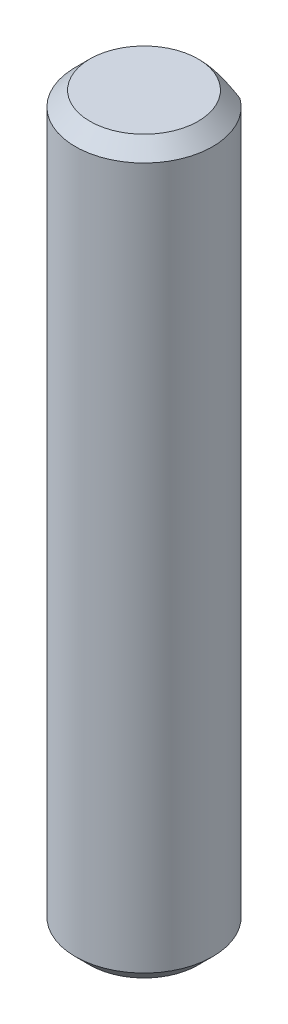
from build123d import *

# Parameters (mm, degrees)
CUT_EXTRUDE1_DEPTH = 26


with BuildPart() as part:
    # Sketch1 → Revolve1 (revolve)
    with BuildSketch(Plane.XY):
        Polygon((0, -12.5), (-1.85, -12.5), (-2.35, -12), (-2.35, 12), (-1.85, 12.5), (0, 12.5), align=None)
    revolve(axis=Axis((0, 12.5, 0), (0, -1, 0)))

    # Sketch2 → Cut-Extrude1 (cut, through all)
    with BuildSketch(Plane(origin=(0, 12.5, 0), x_dir=(1, 0, 0), z_dir=(0, 1, 0))):
        Polygon((-22.69615912, 1.9), (-1.382931669, 1.9), (1.382931669, 1.9), (22.69615912, 1.9), (22.69615912, 44.526454903), (-22.69615912, 44.526454903), align=None)
    extrude(amount=-CUT_EXTRUDE1_DEPTH, mode=Mode.SUBTRACT)


solid = part.part
